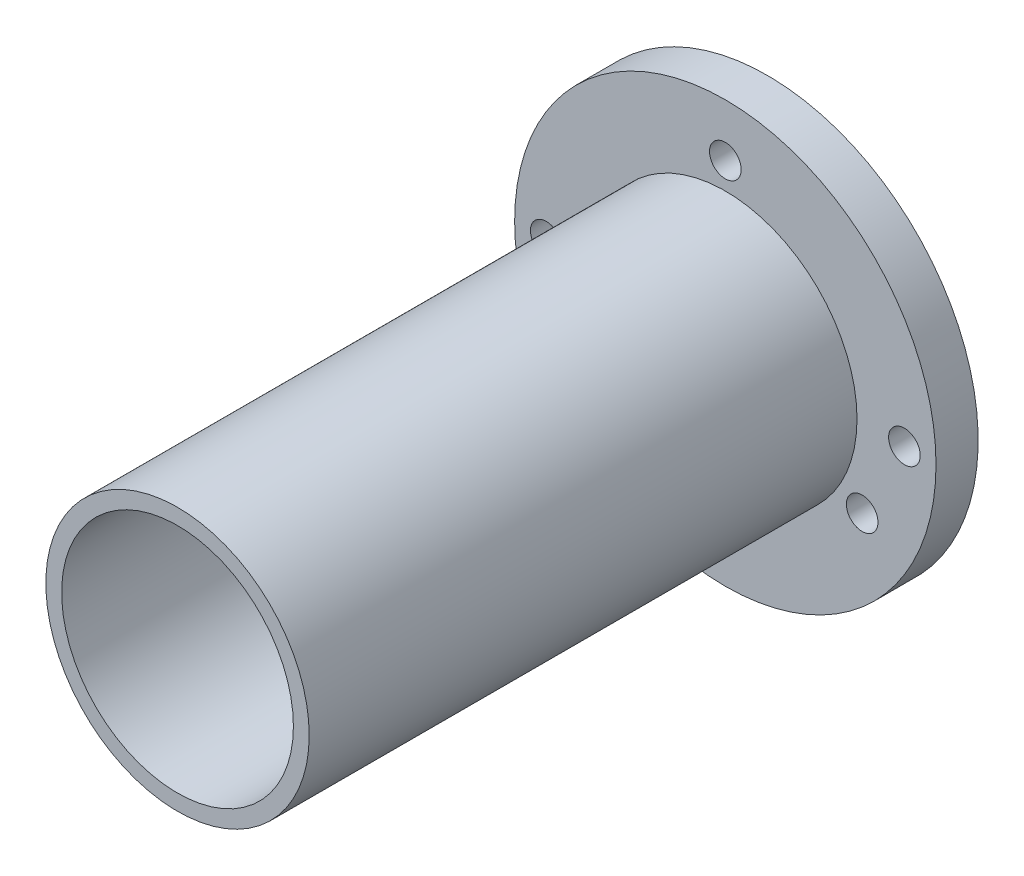
from build123d import *

# Parameters (mm, degrees)
SKETCH1_R           = 10
SKETCH1_R_2         = 5.5
BOSS_EXTRUDE1_DEPTH = 2
SKETCH3_R           = 3
BOSS_EXTRUDE2_DEPTH = 12
SKETCH4_R           = 10
SKETCH4_R_2         = 3
BOSS_EXTRUDE3_DEPTH = 2
CHAMFER2_SIZE       = 1
CHAMFER4_SIZE       = 0.5
CUT_EXTRUDE1_REACH  = 6
SKETCH5_R           = 0.75
SKETCH6_R           = 6.25
SKETCH6_R_2         = 5.5
BOSS_EXTRUDE4_DEPTH = 26
CUT_EXTRUDE2_REACH  = 32
SKETCH7_R           = 0.75
SKETCH8_R           = 16.614534325
CUT_EXTRUDE3_DEPTH  = 12


with BuildPart() as part:
    # Sketch1 → Boss-Extrude1 (new body)
    with BuildSketch(Plane.XY):
        Circle(SKETCH1_R)
        Circle(SKETCH1_R_2, mode=Mode.SUBTRACT)
    extrude(amount=BOSS_EXTRUDE1_DEPTH)



with BuildPart() as body_2:
    # Sketch3 → Boss-Extrude2 (new body)
    with BuildSketch(Plane(origin=(0, 0, 0), x_dir=(-1, 0, 0), z_dir=(0, 0, -1))):
        Circle(SKETCH3_R)
    extrude(amount=BOSS_EXTRUDE2_DEPTH)


with BuildPart() as part_1:
    add(part.part)

    add(body_2.part)  # Boss-Extrude3 merges body 2
    # Sketch4 → Boss-Extrude3 (add)
    with BuildSketch(Plane(origin=(0, 0, 0), x_dir=(-1, 0, 0), z_dir=(0, 0, -1))):
        Circle(SKETCH4_R)
        Circle(SKETCH4_R_2, mode=Mode.SUBTRACT)
    extrude(amount=BOSS_EXTRUDE3_DEPTH)

    # Chamfer2
    chamfer2_edges = [part_1.edges().sort_by_distance(p)[0] for p in [
        (3, 0, -2),
    ]]
    chamfer(chamfer2_edges, length=CHAMFER2_SIZE)

    # Chamfer4
    chamfer4_edges = [part_1.edges().sort_by_distance(p)[0] for p in [
        (3, 0, -12),
    ]]
    chamfer(chamfer4_edges, length=CHAMFER4_SIZE)

    # Sketch5 → Cut-Extrude1 (cut, up to next)
    with BuildSketch(Plane(origin=(0, 0, -2), x_dir=(-1, 0, 0), z_dir=(0, 0, -1)), mode=Mode.PRIVATE) as cut_extrude1_sk1:
        with Locations((-8.5, 0)):
            Circle(SKETCH5_R)
    cut_extrude1_tool1 = extrude(cut_extrude1_sk1.sketch, amount=-CUT_EXTRUDE1_REACH, mode=Mode.PRIVATE) & part_1.part
    add(cut_extrude1_tool1.solids().sort_by_distance((8.5, 0, -2))[0], mode=Mode.SUBTRACT)
    # Sketch5 → Cut-Extrude1 (cut, up to next)
    with BuildSketch(Plane(origin=(0, 0, -2), x_dir=(-1, 0, 0), z_dir=(0, 0, -1)), mode=Mode.PRIVATE) as cut_extrude1_sk2:
        with Locations((8.5, 0)):
            Circle(SKETCH5_R)
    cut_extrude1_tool2 = extrude(cut_extrude1_sk2.sketch, amount=-CUT_EXTRUDE1_REACH, mode=Mode.PRIVATE) & part_1.part
    add(cut_extrude1_tool2.solids().sort_by_distance((-8.5, 0, -2))[0], mode=Mode.SUBTRACT)

    # Sketch6 → Boss-Extrude4 (add)
    with BuildSketch(Plane.XY.offset(2)):
        Circle(SKETCH6_R)
        Circle(SKETCH6_R_2, mode=Mode.SUBTRACT)
    extrude(amount=BOSS_EXTRUDE4_DEPTH)

    # Sketch7 → Cut-Extrude2 (cut, up to next)
    with BuildSketch(Plane(origin=(0, 0, -2), x_dir=(-1, 0, 0), z_dir=(0, 0, -1)), mode=Mode.PRIVATE) as cut_extrude2_sk1:
        with Locations((0, 7.5)):
            Circle(SKETCH7_R)
    cut_extrude2_tool1 = extrude(cut_extrude2_sk1.sketch, amount=-CUT_EXTRUDE2_REACH, mode=Mode.PRIVATE) & part_1.part
    add(cut_extrude2_tool1.solids().sort_by_distance((0, 7.5, -2))[0], mode=Mode.SUBTRACT)
    # Sketch7 → Cut-Extrude2 (cut, up to next)
    with BuildSketch(Plane(origin=(0, 0, -2), x_dir=(-1, 0, 0), z_dir=(0, 0, -1)), mode=Mode.PRIVATE) as cut_extrude2_sk2:
        with Locations((6.495190528, -3.75)):
            Circle(SKETCH7_R)
    cut_extrude2_tool2 = extrude(cut_extrude2_sk2.sketch, amount=-CUT_EXTRUDE2_REACH, mode=Mode.PRIVATE) & part_1.part
    add(cut_extrude2_tool2.solids().sort_by_distance((-6.495191, -3.75, -2))[0], mode=Mode.SUBTRACT)
    # Sketch7 → Cut-Extrude2 (cut, up to next)
    with BuildSketch(Plane(origin=(0, 0, -2), x_dir=(-1, 0, 0), z_dir=(0, 0, -1)), mode=Mode.PRIVATE) as cut_extrude2_sk3:
        with Locations((-6.495190528, -3.75)):
            Circle(SKETCH7_R)
    cut_extrude2_tool3 = extrude(cut_extrude2_sk3.sketch, amount=-CUT_EXTRUDE2_REACH, mode=Mode.PRIVATE) & part_1.part
    add(cut_extrude2_tool3.solids().sort_by_distance((6.495191, -3.75, -2))[0], mode=Mode.SUBTRACT)

    # Sketch8 → Cut-Extrude3 (cut)
    with BuildSketch(Plane(origin=(0, 0, -12), x_dir=(-1, 0, 0), z_dir=(0, 0, -1))):
        Circle(SKETCH8_R)
    extrude(amount=-CUT_EXTRUDE3_DEPTH, mode=Mode.SUBTRACT)


solid = part_1.part
